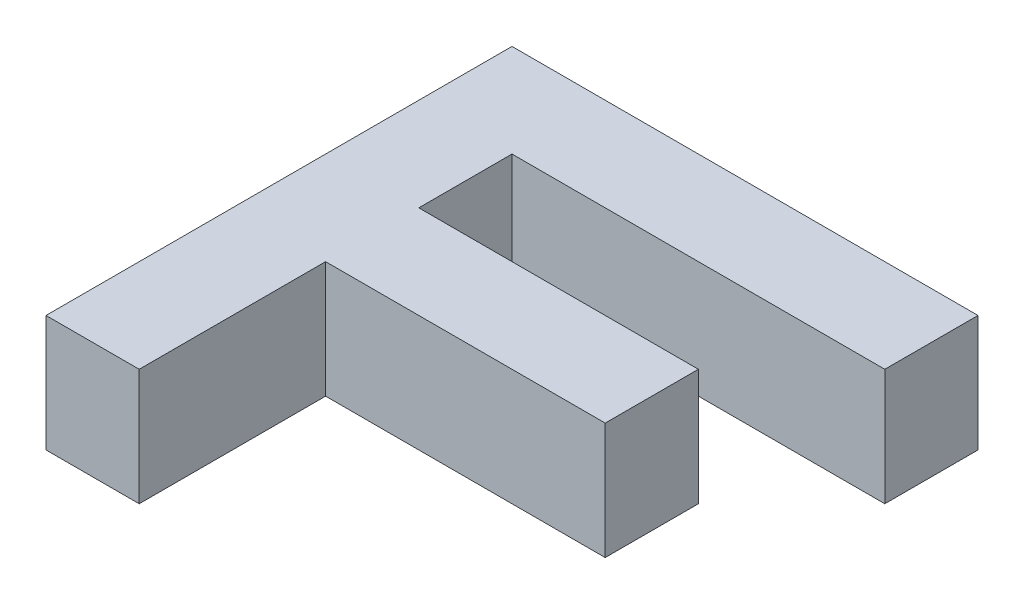
from build123d import *

# Parameters (mm, degrees)
BOSS_EXTRUDE1_DEPTH = 10


with BuildPart() as part:
    # Sketch1 → Boss-Extrude1 (new body)
    with BuildSketch(Plane(origin=(0, 0, 0), x_dir=(1, 0, 0), z_dir=(0, 1, 0))):
        Polygon((250, 0), (250, 40), (290, 40), (290, 32), (258, 32), (258, 24), (282, 24), (282, 16), (258, 16), (258, 0), align=None)
    extrude(amount=BOSS_EXTRUDE1_DEPTH)


solid = part.part
